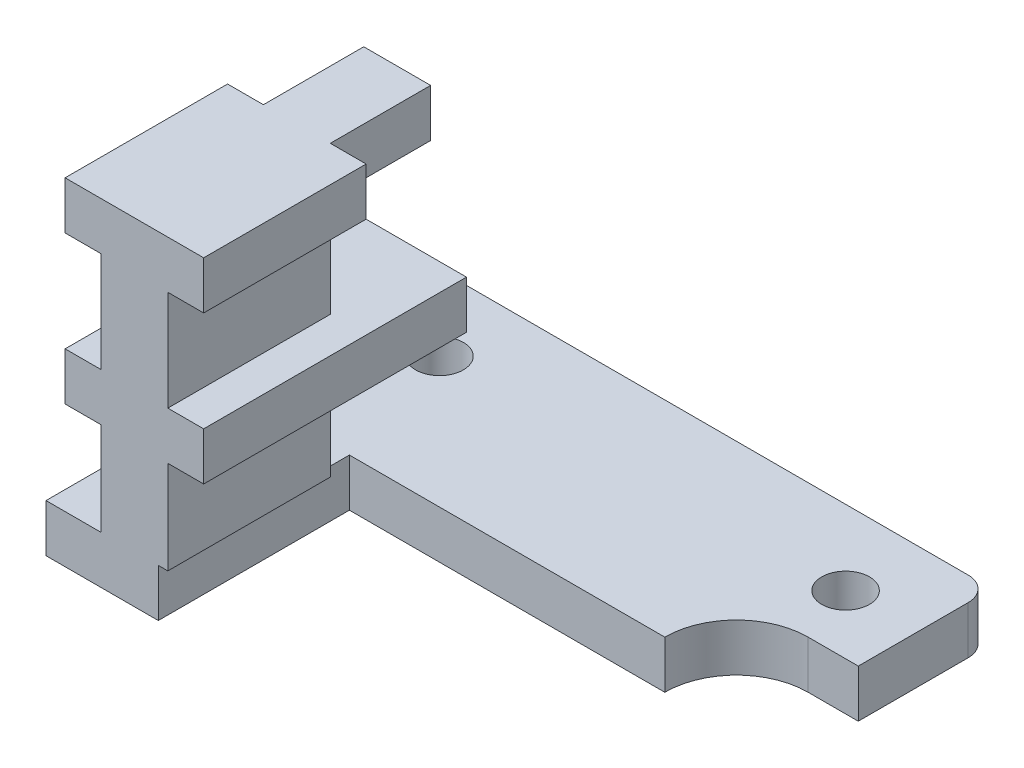
from build123d import *

# Parameters (mm, degrees)
SKETCH1_R           = 1
BOSS_EXTRUDE1_DEPTH = 2
BOSS_EXTRUDE2_START = 8
BOSS_EXTRUDE2_DEPTH = 6.8
SKETCH3_W           = 2.8
SKETCH3_H           = 2
SKETCH3_W_2         = 5.8
BOSS_EXTRUDE3_DEPTH = 11


with BuildPart() as part:
    # Sketch1 → Boss-Extrude1 (new body)
    with BuildSketch(Plane(origin=(0, 0, 0), x_dir=(1, 0, 0), z_dir=(0, 1, 0))):
        with BuildLine():
            Line((11.7, 3), (11.7, 7.6))
            ThreePointArc((11.7, 7.6), (11.407106781, 8.307106781), (10.7, 8.6))
            Line((10.7, 8.6), (-10.3, 8.6))
            ThreePointArc((-10.3, 8.6), (-11.007106781, 8.307106781), (-11.3, 7.6))
            Line((-11.3, 7.6), (-11.3, -8))
            Line((-11.3, -8), (-6.6, -8))
            Line((-6.6, -8), (-6.6, 0))
            Line((-6.6, 0), (6.6, 0))
            ThreePointArc((6.6, 0), (7.478679656, 2.121320344), (9.6, 3))
            Line((9.6, 3), (11.7, 3))
        make_face()
        with Locations((8.7, 5.469565217)):
            Circle(SKETCH1_R, mode=Mode.SUBTRACT)
        with Locations((-8.3, 5.469565217)):
            Circle(SKETCH1_R, mode=Mode.SUBTRACT)
    extrude(amount=BOSS_EXTRUDE1_DEPTH)

    # Sketch2 → Boss-Extrude2 (add)
    with BuildSketch(Plane.XY.offset(BOSS_EXTRUDE2_START)):
        Polygon((-9, 2), (-9, 12.1), (-10.5, 12.1), (-10.5, 14.1), (-4.7, 14.1), (-4.7, 12.1), (-6.2, 12.1), (-6.2, 2), align=None)
    extrude(amount=-BOSS_EXTRUDE2_DEPTH)

    # Sketch3 → Boss-Extrude3 (add)
    with BuildSketch(Plane.XY.offset(8)):
        with Locations((-7.6, 13.1)):
            Rectangle(SKETCH3_W, SKETCH3_H)
        with Locations((-7.6, 6.9)):
            Rectangle(SKETCH3_W_2, SKETCH3_H)
    extrude(amount=-BOSS_EXTRUDE3_DEPTH)


solid = part.part
